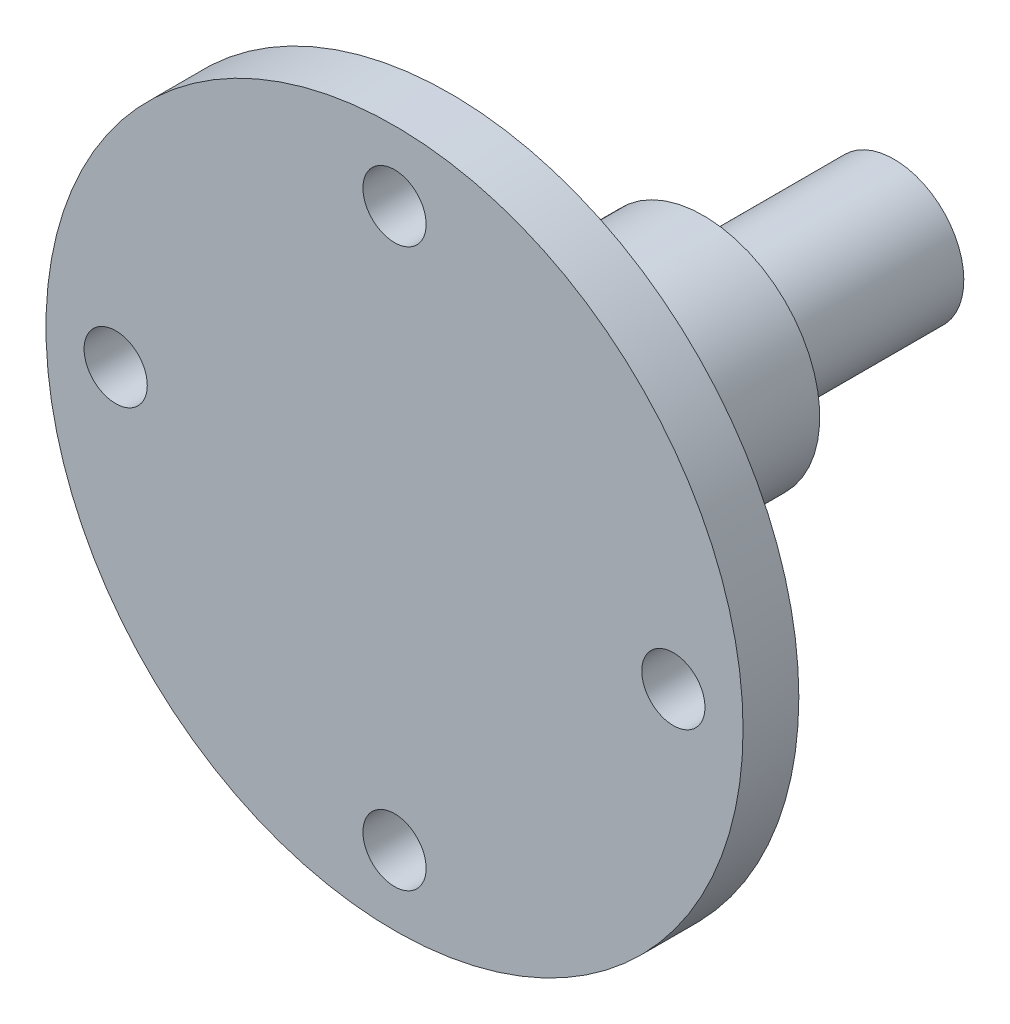
from build123d import *

# Parameters (mm, degrees)
SKETCH1_R                                     = 37.5
BOSS_EXTRUDE1_DEPTH                           = 6
TROU_POUR_TARAUDAGE_POUR_TROU_TARAUD_M8_D     = 6.8
TROU_POUR_TARAUDAGE_POUR_TROU_TARAUD_M8_DEPTH = 23
TROU_POUR_TARAUDAGE_POUR_TROU_TARAUD_M8_TIP   = 2.042926105
SKETCH6_R                                     = 14.5
BOSS_EXTRU_1_DEPTH                            = 6
SKETCH5_R                                     = 12.5
BOSS_EXTRU_2_DEPTH                            = 21.25
ESQUISSE11_R                                  = 7.5
BOSS_EXTRU_6_DEPTH                            = 20.5
TROU_POUR_TARAUDAGE_POUR_TROU_TARAUD_M6_D     = 5
TROU_POUR_TARAUDAGE_POUR_TROU_TARAUD_M6_DEPTH = 24
TROU_POUR_TARAUDAGE_POUR_TROU_TARAUD_M6_TIP   = 1.502151548
ENL_V_MAT_EXTRU_1_DEPTH                       = 34


with BuildPart() as part:
    # Sketch1 → Boss-Extrude1 (new body)
    with BuildSketch(Plane.XY):
        Circle(SKETCH1_R)
    extrude(amount=BOSS_EXTRUDE1_DEPTH)

    # Trou pour taraudage pour trou taraudé M81
    with Locations(Plane.XY.offset(6)):
        with Locations((-30, 0), (0, 30), (30, 0), (0, -30)):
            Hole(TROU_POUR_TARAUDAGE_POUR_TROU_TARAUD_M8_D / 2, depth=TROU_POUR_TARAUDAGE_POUR_TROU_TARAUD_M8_DEPTH)
            with Locations((0, 0, -(TROU_POUR_TARAUDAGE_POUR_TROU_TARAUD_M8_DEPTH + TROU_POUR_TARAUDAGE_POUR_TROU_TARAUD_M8_TIP / 2))):  # 118° drill point
                Cone(0, TROU_POUR_TARAUDAGE_POUR_TROU_TARAUD_M8_D / 2, TROU_POUR_TARAUDAGE_POUR_TROU_TARAUD_M8_TIP, mode=Mode.SUBTRACT)

    # Sketch6 → Boss.-Extru.1 (add)
    with BuildSketch(Plane(origin=(0, 0, 0), x_dir=(-1, 0, 0), z_dir=(0, 0, -1))):
        Circle(SKETCH6_R)
    extrude(amount=BOSS_EXTRU_1_DEPTH)

    # Sketch5 → Boss.-Extru.2 (add)
    with BuildSketch(Plane(origin=(0, 0, -6), x_dir=(-1, 0, 0), z_dir=(0, 0, -1))):
        Circle(SKETCH5_R)
    extrude(amount=BOSS_EXTRU_2_DEPTH)

    # Esquisse11 → Boss.-Extru.6 (add)
    with BuildSketch(Plane(origin=(0, 0, -27.25), x_dir=(-1, 0, 0), z_dir=(0, 0, -1))):
        Circle(ESQUISSE11_R)
    extrude(amount=BOSS_EXTRU_6_DEPTH)

    # Trou pour taraudage pour trou taraudé M61
    with Locations(Plane(origin=(0, 0, -47.75), x_dir=(-1, 0, 0), z_dir=(0, 0, -1))):
        with Locations((0, 0)):
            Hole(TROU_POUR_TARAUDAGE_POUR_TROU_TARAUD_M6_D / 2, depth=TROU_POUR_TARAUDAGE_POUR_TROU_TARAUD_M6_DEPTH)
            with Locations((0, 0, -(TROU_POUR_TARAUDAGE_POUR_TROU_TARAUD_M6_DEPTH + TROU_POUR_TARAUDAGE_POUR_TROU_TARAUD_M6_TIP / 2))):  # 118° drill point
                Cone(0, TROU_POUR_TARAUDAGE_POUR_TROU_TARAUD_M6_D / 2, TROU_POUR_TARAUDAGE_POUR_TROU_TARAUD_M6_TIP, mode=Mode.SUBTRACT)

    # Esquisse5 → Enlèv. mat.-Extru.1 (cut, through all)
    with BuildSketch(Plane(origin=(0, -4.5, 0), x_dir=(1, 0, 0), z_dir=(0, 1, 0))):
        with BuildLine():
            Line((2.5, 47.75), (2.5, 30.75))
            ThreePointArc((2.5, 30.75), (0, 28.25), (-2.5, 30.75))
            Line((-2.5, 30.75), (-2.5, 47.75))
            ThreePointArc((-2.5, 47.75), (0, 50.25), (2.5, 47.75))
        make_face()
    extrude(amount=-ENL_V_MAT_EXTRU_1_DEPTH, mode=Mode.SUBTRACT)


solid = part.part
